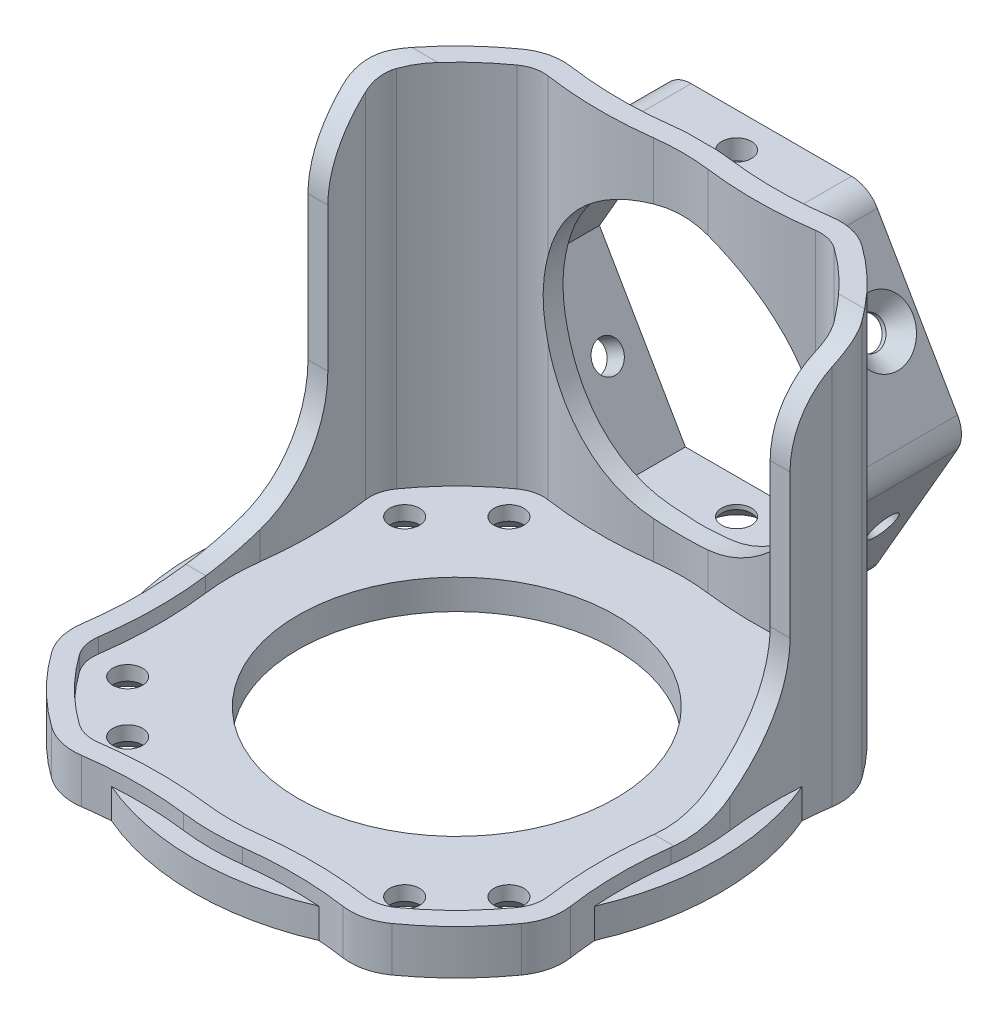
from build123d import *

# Parameters (mm, degrees)
SKETCH_1_R               = 26.5
SKETCH_1_R_2             = 16
SKETCH_1_R_3             = 1.5
EXTRUDE_1_DEPTH          = 3
EXTRUDE_2_DEPTH          = 37
EXTRUDE_2_DEPTH_BACK     = 3
CUT_EXTRUDE_1_DEPTH      = 27.5
CUT_EXTRUDE_1_DEPTH_BACK = 27.5
SKETCH_5_R               = 14
CUT_EXTRUDE_2_DEPTH      = 45
CUT_EXTRUDE_3_DEPTH      = 45
EXTRUDE_3_DEPTH          = 7
EXTRUDE_3_DEPTH_BACK     = 6
CUT_EXTRUDE_4_DEPTH      = 37
SKETCH_9_R               = 1.5
CUT_EXTRUDE_5_DEPTH      = 50.69967325
SKETCH_10_R              = 1.5
CUT_EXTRUDE_6_DEPTH      = 51.19967325
SKETCH_11_R              = 1.5
CUT_EXTRUDE_7_DEPTH      = 38.5000001
EXTRUDE_4_DEPTH          = 3
CHAMFER_1_SIZE           = 1.55
CHAMFER_2_SIZE           = 1.55


with BuildPart() as part:
    # 草图1 → 凸台-拉伸1 (new body)
    with BuildSketch(Plane(origin=(0, 0, 0), x_dir=(1, 0, 0), z_dir=(0, 1, 0))):
        Circle(SKETCH_1_R)
        Circle(SKETCH_1_R_2, mode=Mode.SUBTRACT)
        with Locations((-19.214153616, 13.959899742)):
            Circle(SKETCH_1_R_3, mode=Mode.SUBTRACT)
        with Locations((-13.959899742, 19.214153616)):
            Circle(SKETCH_1_R_3, mode=Mode.SUBTRACT)
        with Locations((13.959899742, 19.214153616)):
            Circle(SKETCH_1_R_3, mode=Mode.SUBTRACT)
        with Locations((19.214153616, 13.959899742)):
            Circle(SKETCH_1_R_3, mode=Mode.SUBTRACT)
        with Locations((19.214153616, -13.959899742)):
            Circle(SKETCH_1_R_3, mode=Mode.SUBTRACT)
        with Locations((13.959899742, -19.214153616)):
            Circle(SKETCH_1_R_3, mode=Mode.SUBTRACT)
        with Locations((-19.214153616, -13.959899742)):
            Circle(SKETCH_1_R_3, mode=Mode.SUBTRACT)
        with Locations((-13.959899742, -19.214153616)):
            Circle(SKETCH_1_R_3, mode=Mode.SUBTRACT)
    extrude(amount=EXTRUDE_1_DEPTH)

    # 草图3 → 凸台-拉伸2 (add, two sides)
    with BuildSketch(Plane(origin=(0, 3, 0), x_dir=(1, 0, 0), z_dir=(0, 1, 0))) as extrude_2_sk:
        with BuildLine():
            ThreePointArc((-2.989428969, -24.56110809), (0, -24.75), (2.989428969, -24.56110809))
            ThreePointArc((2.989428969, -24.56110809), (8.087147371, -24.260183601), (13.179183812, -24.645480021))
            ThreePointArc((13.179183812, -24.645480021), (15.260694269, -24.544890664), (17.154582131, -23.675412218))
            ThreePointArc((17.154582131, -23.675412218), (18.980091216, -22.251492125), (20.68287335, -20.68287335))
            ThreePointArc((20.68287335, -20.68287335), (22.251492125, -18.980091216), (23.675412218, -17.154582131))
            ThreePointArc((23.675412218, -17.154582131), (24.544890664, -15.260694269), (24.645480021, -13.179183812))
            ThreePointArc((24.645480021, -13.179183812), (24.260183601, -8.087147371), (24.56110809, -2.989428969))
            ThreePointArc((24.56110809, -2.989428969), (24.75, 0), (24.56110809, 2.989428969))
            ThreePointArc((24.56110809, 2.989428969), (24.260183601, 8.087147371), (24.645480021, 13.179183812))
            ThreePointArc((24.645480021, 13.179183812), (24.544890664, 15.260694269), (23.675412218, 17.154582131))
            ThreePointArc((23.675412218, 17.154582131), (22.251492125, 18.980091216), (20.68287335, 20.68287335))
            ThreePointArc((20.68287335, 20.68287335), (18.980091216, 22.251492125), (17.154582131, 23.675412218))
            ThreePointArc((17.154582131, 23.675412218), (15.260694269, 24.544890664), (13.179183812, 24.645480021))
            ThreePointArc((13.179183812, 24.645480021), (8.087147371, 24.260183601), (2.989428969, 24.56110809))
            ThreePointArc((2.989428969, 24.56110809), (0, 24.75), (-2.989428969, 24.56110809))
            ThreePointArc((-2.989428969, 24.56110809), (-8.087147371, 24.260183601), (-13.179183812, 24.645480021))
            ThreePointArc((-13.179183812, 24.645480021), (-15.260694269, 24.544890664), (-17.154582131, 23.675412218))
            ThreePointArc((-17.154582131, 23.675412218), (-18.980091216, 22.251492125), (-20.68287335, 20.68287335))
            ThreePointArc((-20.68287335, 20.68287335), (-22.251492125, 18.980091216), (-23.675412218, 17.154582131))
            ThreePointArc((-23.675412218, 17.154582131), (-24.544890664, 15.260694269), (-24.645480021, 13.179183812))
            ThreePointArc((-24.645480021, 13.179183812), (-24.260183601, 8.087147371), (-24.56110809, 2.989428969))
            ThreePointArc((-24.56110809, 2.989428969), (-24.75, 0), (-24.56110809, -2.989428969))
            ThreePointArc((-24.56110809, -2.989428969), (-24.260183601, -8.087147371), (-24.645480021, -13.179183812))
            ThreePointArc((-24.645480021, -13.179183812), (-24.544890664, -15.260694269), (-23.675412218, -17.154582131))
            ThreePointArc((-23.675412218, -17.154582131), (-22.251492125, -18.980091216), (-20.68287335, -20.68287335))
            ThreePointArc((-20.68287335, -20.68287335), (-18.980091216, -22.251492125), (-17.154582131, -23.675412218))
            ThreePointArc((-17.154582131, -23.675412218), (-15.260694269, -24.544890664), (-13.179183812, -24.645480021))
            ThreePointArc((-13.179183812, -24.645480021), (-8.087147371, -24.260183601), (-2.989428969, -24.56110809))
        make_face()
        with BuildLine():
            ThreePointArc((-2.737687583, -22.577014777), (0, -22.75), (2.737687583, -22.577014777))
            ThreePointArc((2.737687583, -22.577014777), (8.103706953, -22.260252157), (13.463745312, -22.665827336))
            ThreePointArc((13.463745312, -22.665827336), (14.78657042, -22.601901581), (15.990159097, -22.049337497))
            ThreePointArc((15.990159097, -22.049337497), (19.268659787, -19.268659787), (22.049337497, -15.990159097))
            ThreePointArc((22.049337497, -15.990159097), (22.601901581, -14.78657042), (22.665827336, -13.463745312))
            ThreePointArc((22.665827336, -13.463745312), (22.260252157, -8.103706953), (22.577014777, -2.737687583))
            ThreePointArc((22.577014777, -2.737687583), (22.75, 0), (22.577014777, 2.737687583))
            ThreePointArc((22.577014777, 2.737687583), (22.260252157, 8.103706953), (22.665827336, 13.463745312))
            ThreePointArc((22.665827336, 13.463745312), (22.601901581, 14.78657042), (22.049337497, 15.990159097))
            ThreePointArc((22.049337497, 15.990159097), (19.268659787, 19.268659787), (15.990159097, 22.049337497))
            ThreePointArc((15.990159097, 22.049337497), (14.78657042, 22.601901581), (13.463745312, 22.665827336))
            ThreePointArc((13.463745312, 22.665827336), (8.103706953, 22.260252157), (2.737687583, 22.577014777))
            ThreePointArc((2.737687583, 22.577014777), (0, 22.75), (-2.737687583, 22.577014777))
            ThreePointArc((-2.737687583, 22.577014777), (-8.103706953, 22.260252157), (-13.463745312, 22.665827336))
            ThreePointArc((-13.463745312, 22.665827336), (-14.78657042, 22.601901581), (-15.990159097, 22.049337497))
            ThreePointArc((-15.990159097, 22.049337497), (-19.268659787, 19.268659787), (-22.049337497, 15.990159097))
            ThreePointArc((-22.049337497, 15.990159097), (-22.601901581, 14.78657042), (-22.665827336, 13.463745312))
            ThreePointArc((-22.665827336, 13.463745312), (-22.260252157, 8.103706953), (-22.577014777, 2.737687583))
            ThreePointArc((-22.577014777, 2.737687583), (-22.75, 0), (-22.577014777, -2.737687583))
            ThreePointArc((-22.577014777, -2.737687583), (-22.260252157, -8.103706953), (-22.665827336, -13.463745312))
            ThreePointArc((-22.665827336, -13.463745312), (-22.601901581, -14.78657042), (-22.049337497, -15.990159097))
            ThreePointArc((-22.049337497, -15.990159097), (-19.268659787, -19.268659787), (-15.990159097, -22.049337497))
            ThreePointArc((-15.990159097, -22.049337497), (-14.78657042, -22.601901581), (-13.463745312, -22.665827336))
            ThreePointArc((-13.463745312, -22.665827336), (-8.103706953, -22.260252157), (-2.737687583, -22.577014777))
        make_face(mode=Mode.SUBTRACT)
    extrude(amount=EXTRUDE_2_DEPTH)
    extrude(extrude_2_sk.sketch, amount=-EXTRUDE_2_DEPTH_BACK)

    # 草图4 → 切除-拉伸1 (cut, two sides)
    with BuildSketch(Plane(origin=(0, 0, 0), x_dir=(0, 0, -1), z_dir=(1, 0, 0))) as cut_extrude_1_sk:
        with BuildLine():
            Line((-27.904733648, 4.5), (-2.706623909, 4.5))
            ThreePointArc((-2.706623909, 4.5), (5.778657465, 8.014718626), (9.293376091, 16.5))
            Line((9.293376091, 16.5), (9.293376091, 31))
            ThreePointArc((9.293376091, 31), (11.92941506, 37.363961031), (18.293376091, 40))
            Line((18.293376091, 40), (24.701304414, 40))
            Line((24.701304414, 40), (24.701304414, -2.023759682))
            Line((24.701304414, -2.023759682), (30.543576993, -2.023759682))
            Line((30.543576993, -2.023759682), (30.543576993, 47.053629239))
            Line((30.543576993, 47.053629239), (-27.904733648, 47.053629239))
            Line((-27.904733648, 47.053629239), (-27.904733648, 4.5))
        make_face()
    extrude(amount=CUT_EXTRUDE_1_DEPTH, mode=Mode.SUBTRACT)
    extrude(cut_extrude_1_sk.sketch, amount=-CUT_EXTRUDE_1_DEPTH_BACK, mode=Mode.SUBTRACT)

    # 草图5 → 切除-拉伸2 (cut)
    with BuildSketch(Plane(origin=(0, 0, -24.701304414), x_dir=(-1, 0, 0), z_dir=(0, 0, -1))):
        with Locations((0, 20.5)):
            Circle(SKETCH_5_R)
    extrude(amount=-CUT_EXTRUDE_2_DEPTH, mode=Mode.SUBTRACT)

    # 草图6 → 切除-拉伸3 (cut)
    with BuildSketch(Plane(origin=(0, 40, 0), x_dir=(1, 0, 0), z_dir=(0, 1, 0))):
        with BuildLine():
            Line((-13.179183812, 24.645480021), (-10.49229509, 27.332368743))
            Line((-10.49229509, 27.332368743), (-4.706798363, 27.332368743))
            Line((-4.706798363, 27.332368743), (-1.520088512, 24.701304414))
            ThreePointArc((-1.520088512, 24.701304414), (-2.255848118, 24.64262357), (-2.989428969, 24.56110809))
            ThreePointArc((-2.989428969, 24.56110809), (-8.087147371, 24.260183601), (-13.179183812, 24.645480021))
        make_face()
        with BuildLine():
            Line((1.520088512, 24.701304414), (2.770670622, 27.332368743))
            Line((2.770670622, 27.332368743), (10.443204015, 27.041186182))
            Line((10.443204015, 27.041186182), (13.179183812, 24.645480021))
            ThreePointArc((13.179183812, 24.645480021), (8.087147371, 24.260183601), (2.989428969, 24.56110809))
            ThreePointArc((2.989428969, 24.56110809), (2.255848118, 24.64262357), (1.520088512, 24.701304414))
        make_face()
    extrude(amount=-CUT_EXTRUDE_3_DEPTH, mode=Mode.SUBTRACT)

    # 草图7 → 凸台-拉伸3 (add, two sides)
    with BuildSketch(Plane(origin=(0, 0, -24.701304414), x_dir=(-1, 0, 0), z_dir=(0, 0, -1))) as extrude_3_sk:
        with BuildLine():
            Line((10.68097998, 5), (18.763883749, 19))
            ThreePointArc((18.763883749, 19), (19.165807537, 20.5), (18.763883749, 22))
            Line((18.763883749, 22), (10.68097998, 36))
            ThreePointArc((10.68097998, 36), (9.582903769, 37.098076211), (8.082903769, 37.5))
            Line((8.082903769, 37.5), (-8.082903769, 37.5))
            ThreePointArc((-8.082903769, 37.5), (-9.582903769, 37.098076211), (-10.68097998, 36))
            Line((-10.68097998, 36), (-18.763883749, 22))
            ThreePointArc((-18.763883749, 22), (-19.165807537, 20.5), (-18.763883749, 19))
            Line((-18.763883749, 19), (-10.68097998, 5))
            ThreePointArc((-10.68097998, 5), (-9.582903769, 3.901923789), (-8.082903769, 3.5))
            Line((-8.082903769, 3.5), (8.082903769, 3.5))
            ThreePointArc((8.082903769, 3.5), (9.582903769, 3.901923789), (10.68097998, 5))
        make_face()
        Polygon((8.660254038, 5.5), (17.320508076, 20.5), (8.660254038, 35.5), (-8.660254038, 35.5), (-17.320508076, 20.5), (-8.660254038, 5.5), align=None, mode=Mode.SUBTRACT)
    extrude(amount=EXTRUDE_3_DEPTH)
    extrude(extrude_3_sk.sketch, amount=-EXTRUDE_3_DEPTH_BACK)

    # 草图8 → 切除-拉伸4 (cut)
    with BuildSketch(Plane(origin=(0, 40, 0), x_dir=(1, 0, 0), z_dir=(0, 1, 0))):
        with BuildLine():
            Line((-22.049337497, 15.990159097), (22.049337497, 15.990159097))
            ThreePointArc((22.049337497, 15.990159097), (19.268659787, 19.268659787), (15.990159097, 22.049337497))
            ThreePointArc((15.990159097, 22.049337497), (14.78657042, 22.601901581), (13.463745312, 22.665827336))
            ThreePointArc((13.463745312, 22.665827336), (8.103706953, 22.260252157), (2.737687583, 22.577014777))
            ThreePointArc((2.737687583, 22.577014777), (0, 22.75), (-2.737687583, 22.577014777))
            ThreePointArc((-2.737687583, 22.577014777), (-8.103706953, 22.260252157), (-13.463745312, 22.665827336))
            ThreePointArc((-13.463745312, 22.665827336), (-14.78657042, 22.601901581), (-15.990159097, 22.049337497))
            ThreePointArc((-15.990159097, 22.049337497), (-19.268659787, 19.268659787), (-22.049337497, 15.990159097))
        make_face()
    extrude(amount=-CUT_EXTRUDE_4_DEPTH, mode=Mode.SUBTRACT)

    # 草图9 → 切除-拉伸5 (cut, through all)
    with BuildSketch(Plane(origin=(5.845671476, -3.375, 0), x_dir=(0, 0, -1), z_dir=(0.866025404, -0.5, 0))):
        with Locations((28.201304414, 17.753520778)):
            Circle(SKETCH_9_R)
    extrude(amount=-CUT_EXTRUDE_5_DEPTH, mode=Mode.SUBTRACT)

    # 草图10 → 切除-拉伸6 (cut, through all)
    with BuildSketch(Plane(origin=(23.599192253, 13.625, 0), x_dir=(0, 0, -1), z_dir=(0.866025404, 0.5, 0))):
        with Locations((28.201304414, 17.753520778)):
            Circle(SKETCH_10_R)
    extrude(amount=-CUT_EXTRUDE_6_DEPTH, mode=Mode.SUBTRACT)

    # 草图11 → 切除-拉伸7 (cut, through all)
    with BuildSketch(Plane(origin=(0, 37.5, 0), x_dir=(1, 0, 0), z_dir=(0, 1, 0))):
        with Locations((0, 28.201304414)):
            Circle(SKETCH_11_R)
    extrude(amount=-CUT_EXTRUDE_7_DEPTH, mode=Mode.SUBTRACT)

    # 草图13 → 凸台-拉伸4 (add)
    with BuildSketch(Plane.XZ):
        Polygon((-15.341402032, 23.770487779), (-23.877254163, 15.234635647), (-23.877254163, 12.421142487), (-21.993644335, 13.351025819), (-19.609328097, 16.855970689), (-16.211677458, 20.253621328), (-13.274523151, 21.703608897), (-13.274523151, 23.770487779), align=None)
        Polygon((-23.54344989, -13.138727582), (-22.589723395, -16.810574589), (-20.801486216, -19.5286951), (-18.715209508, -21.614971808), (-16.211677458, -22.866737833), (-13.989494725, -23.977829199), (-12.623281521, -23.977829199), (-12.623281521, -21.614971808), (-14.743100305, -21.245402791), (-16.544370398, -19.444132698), (-20.531815367, -15.456687728), (-23.066586642, -11.60383539), align=None)
        Polygon((12.423362842, -21.614971808), (13.037092034, -23.977829199), (15.842735104, -23.24909074), (19.67120214, -20.730362426), (22.167421777, -17.450410213), (23.407355141, -14.970543485), (23.407355141, -13.530261559), (21.881176363, -13.056105412), (20.680885204, -15.456687728), (18.910696422, -17.226876511), (16.725087857, -19.09038632), (15.167198677, -20.648275499), (13.697820288, -21.614971808), align=None)
        Polygon((12.423362842, 23.09723184), (13.483217316, 22.037377366), (15.458757579, 20.533885218), (17.057111002, 19.317452496), (18.159819524, 17.641335542), (19.586108776, 16.21504629), (20.309695846, 14.984490989), (22.009515957, 13.690836672), (23.096269391, 12.863758994), (23.568943726, 15.574981766), (21.920277396, 18.378756428), (19.08850757, 20.533885218), (16.725087857, 22.332574441), (14.760638879, 23.314798929), align=None)
    extrude(amount=-EXTRUDE_4_DEPTH)

    # 倒角1
    chamfer_1_edges = [part.edges().sort_by_distance(p)[0] for p in [
        (-15.459899742, 0, -19.214153616),
        (12.459899742, 0, -19.214153616),
        (17.714153616, 0, -13.959899742),
        (17.818927229, 0, 13.409133614),
        (12.459899742, 0, 19.214153616),
        (-20.714153616, 0, 13.959899742),
        (-15.459899742, 0, 19.214153616),
        (-20.714153616, 0, -13.959899742),
    ]]
    chamfer(chamfer_1_edges, length=CHAMFER_1_SIZE)

    # 倒角2
    chamfer_2_edges = [part.edges().sort_by_distance(p)[0] for p in [
        (-14.722431864, 29, -26.701304414),
        (14.722431864, 29, -26.701304414),
        (-1.5, 3.5, -28.201304414),
    ]]
    chamfer(chamfer_2_edges, length=CHAMFER_2_SIZE)


solid = part.part
